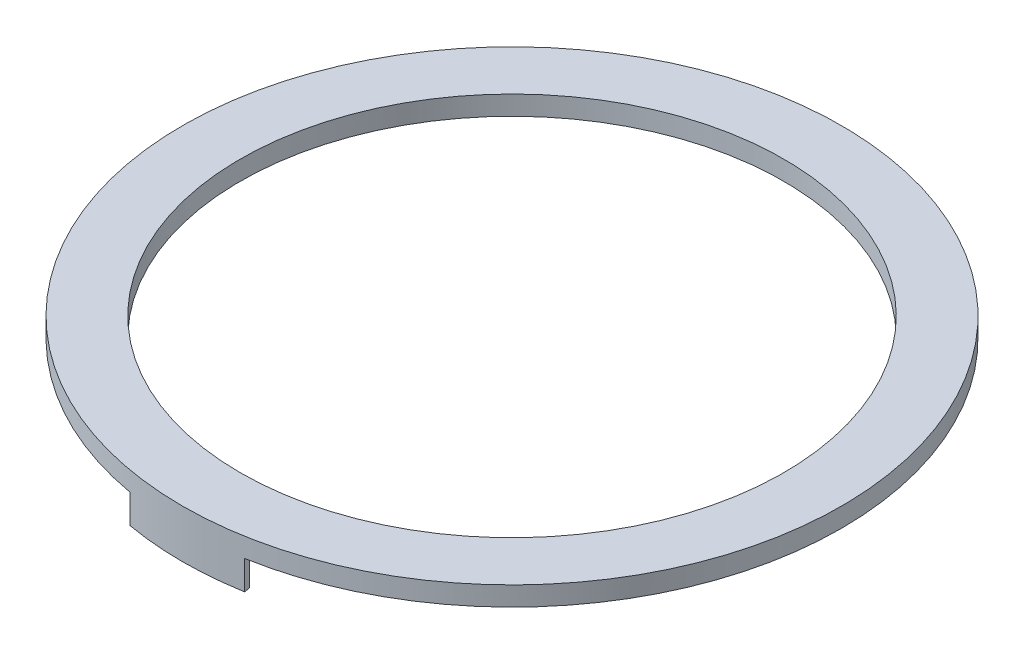
from build123d import *

# Parameters (mm, degrees)
SKETCH1_R           = 171
BOSS_EXTRUDE1_DEPTH = 10
SKETCH2_R           = 141
CUT_EXTRUDE1_DEPTH  = 11
BOSS_EXTRUDE2_DEPTH = 15
BOSS_EXTRUDE3_DEPTH = 15


with BuildPart() as part:
    # Sketch1 → Boss-Extrude1 (new body)
    with BuildSketch(Plane(origin=(0, 0, 0), x_dir=(1, 0, 0), z_dir=(0, 1, 0))):
        Circle(SKETCH1_R)
    extrude(amount=BOSS_EXTRUDE1_DEPTH)

    # Sketch2 → Cut-Extrude1 (cut, through all)
    with BuildSketch(Plane(origin=(0, 10, 0), x_dir=(1, 0, 0), z_dir=(0, 1, 0))):
        Circle(SKETCH2_R)
    extrude(amount=-CUT_EXTRUDE1_DEPTH, mode=Mode.SUBTRACT)

    # Sketch3 → Boss-Extrude2 (add)
    with BuildSketch(Plane.XZ):
        with BuildLine():
            Line((29.693838381, 168.402125765), (29.172893848, 165.447702506))
            ThreePointArc((29.172893848, 165.447702506), (14.689274555, 167.356581027), (0.094580612, 167.999973377))
            ThreePointArc((0.094580612, 167.999973377), (-14.547941757, 167.368926001), (-29.079745505, 165.464100038))
            Line((-29.079745505, 165.464100038), (-29.730542301, 168.395649749))
            ThreePointArc((-29.730542301, 168.395649749), (-14.940760682, 170.346040959), (-0.037270853, 170.999995938))
            ThreePointArc((-0.037270853, 170.999995938), (14.885067408, 170.350916547), (29.693838381, 168.402125765))
        make_face()
    extrude(amount=BOSS_EXTRUDE2_DEPTH)

    # Sketch4 → Boss-Extrude3 (add)
    with BuildSketch(Plane.XZ):
        with BuildLine():
            Line((29.712190517, -168.398888757), (29.120639245, -165.456907894))
            ThreePointArc((29.120639245, -165.456907894), (14.566625791, -167.367300907), (-0.098592842, -167.99997107))
            ThreePointArc((-0.098592842, -167.99997107), (-14.740379926, -167.352087527), (-29.269983819, -165.430553548))
            Line((-29.269983819, -165.430553548), (-29.675485892, -168.405360773))
            ThreePointArc((-29.675485892, -168.405360773), (-14.885067408, -170.350916547), (0.018635427, -170.999998985))
            ThreePointArc((0.018635427, -170.999998985), (14.922196434, -170.347668178), (29.712190517, -168.398888757))
        make_face()
    extrude(amount=BOSS_EXTRUDE3_DEPTH)


solid = part.part
